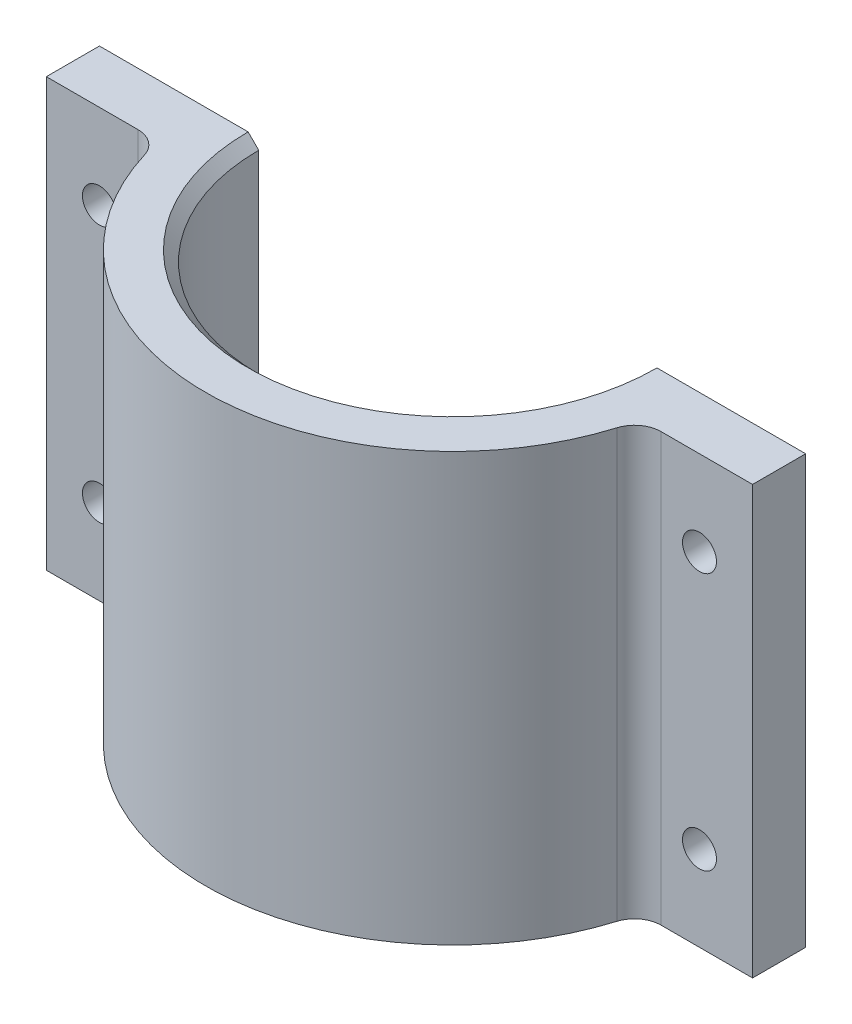
from build123d import *

# Parameters (mm, degrees)
EXTRUDE_1_DEPTH     = 40.25
SKETCH_2_W          = 10
SKETCH_2_H          = 40.25
EXTRUDE_2_DEPTH     = 5
EXTRUDE_2_2_DEPTH   = 5
EXTRUDE_3_DEPTH     = 40.25
CHAMFER_1_SIZE      = 1
SKETCH_4_R          = 1.6
CUT_EXTRUDE_1_DEPTH = 24.25


with BuildPart() as part:
    # Эскиз1 → Бобышка-Вытянуть1 (new body)
    with BuildSketch(Plane(origin=(0, 0, 0), x_dir=(1, 0, 0), z_dir=(0, 1, 0))):
        with BuildLine():
            Line((-23.25, 0), (-18.25, 0))
            ThreePointArc((-18.25, 0), (0, -18.25), (18.25, 0))
            Line((18.25, 0), (23.25, 0))
            ThreePointArc((23.25, 0), (0, -23.25), (-23.25, 0))
        make_face()
    extrude(amount=EXTRUDE_1_DEPTH)



with BuildPart() as body_2:
    # Эскиз2 → Бобышка-Вытянуть2 (new body)
    with BuildSketch(Plane(origin=(0, 0, 0), x_dir=(-1, 0, 0), z_dir=(0, 0, -1))):
        with Locations((-28.25, 20.125)):
            Rectangle(SKETCH_2_W, SKETCH_2_H)
    extrude(amount=-EXTRUDE_2_DEPTH)


with BuildPart() as body_3:
    # Эскиз2 → Extrude 2 2 (new body)
    with BuildSketch(Plane(origin=(0, 0, 0), x_dir=(-1, 0, 0), z_dir=(0, 0, -1))):
        with Locations((28.25, 20.125)):
            Rectangle(SKETCH_2_W, SKETCH_2_H)
    extrude(amount=-EXTRUDE_2_2_DEPTH)


with BuildPart() as part_1:
    add(part.part)

    add(body_2.part)  # Бобышка-Вытянуть3 merges body 2

    add(body_3.part)  # Бобышка-Вытянуть3 merges body 3
    # Эскиз3 → Бобышка-Вытянуть3 (add)
    with BuildSketch(Plane(origin=(0, 40.25, 0), x_dir=(1, 0, 0), z_dir=(0, 1, 0))):
        with BuildLine():
            Line((23.25, -5), (23.25, 0))
            ThreePointArc((23.25, 0), (22.996608271, -3.423230646), (22.241956297, -6.77184466))
            ThreePointArc((22.241956297, -6.77184466), (23.14534213, -5.491220725), (24.6335645, -5))
            Line((24.6335645, -5), (23.25, -5))
        make_face()
        with BuildLine():
            Line((-23.25, -5), (-23.25, 0))
            ThreePointArc((-23.25, 0), (-22.996608271, -3.423230646), (-22.241956297, -6.77184466))
            ThreePointArc((-22.241956297, -6.77184466), (-23.14534213, -5.491220725), (-24.6335645, -5))
            Line((-24.6335645, -5), (-23.25, -5))
        make_face()
    extrude(amount=-EXTRUDE_3_DEPTH)

    # Фаска1
    chamfer_1_edges = [part_1.edges().sort_by_distance(p)[0] for p in [
        (0, 40.25, 18.25),
    ]]
    chamfer(chamfer_1_edges, length=CHAMFER_1_SIZE)

    # Эскиз4 → Вырез-Вытянуть1 (cut, through all)
    with BuildSketch(Plane(origin=(0, 0, 0), x_dir=(-1, 0, 0), z_dir=(0, 0, -1))):
        with Locations((28.25, 32.25)):
            Circle(SKETCH_4_R)
        with Locations((28.25, 8)):
            Circle(SKETCH_4_R)
        with Locations((-28.25, 32.25)):
            Circle(SKETCH_4_R)
        with Locations((-28.25, 8)):
            Circle(SKETCH_4_R)
    extrude(amount=-CUT_EXTRUDE_1_DEPTH, mode=Mode.SUBTRACT)


solid = part_1.part
